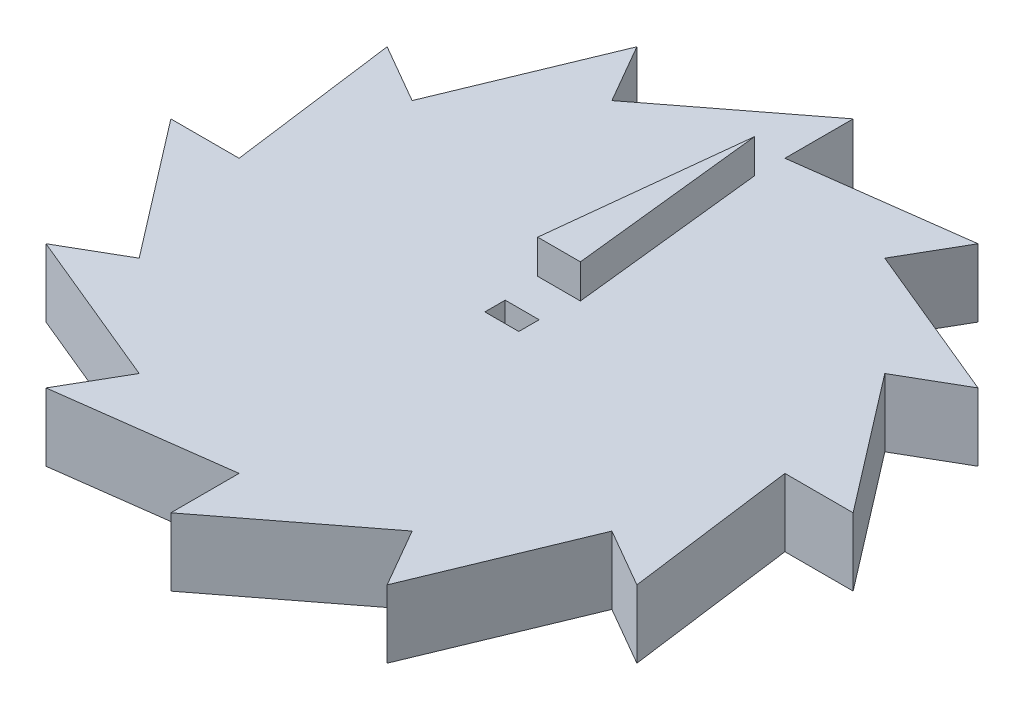
from build123d import *

# Parameters (mm, degrees)
SKETCH2_W           = 5
SKETCH2_H           = 3
BOSS_EXTRUDE2_DEPTH = 10
BOSS_EXTRUDE3_DEPTH = 5


with BuildPart() as part:
    # Sketch2 → Boss-Extrude2 (new body)
    with BuildSketch(Plane(origin=(0, 0, 0), x_dir=(1, 0, 0), z_dir=(0, 1, 0))):
        Polygon((0, 40.223426607), (0, 50.279283258), (-20.111713303, 34.834509269), (-25.139641629, 43.543136586), (-34.834509269, 20.111713303), (-43.543136586, 25.139641629), (-40.223426607, 0), (-50.279283258, 0), (-34.834509269, -20.111713303), (-43.543136586, -25.139641629), (-20.111713303, -34.834509269), (-25.139641629, -43.543136586), (0, -40.223426607), (0, -50.279283258), (20.111713303, -34.834509269), (25.139641629, -43.543136586), (34.834509269, -20.111713303), (43.543136586, -25.139641629), (40.223426607, 0), (50.279283258, 0), (34.834509269, 20.111713303), (43.543136586, 25.139641629), (20.111713303, 34.834509269), (25.139641629, 43.543136586), align=None)
        Rectangle(SKETCH2_W, SKETCH2_H, mode=Mode.SUBTRACT)
    extrude(amount=BOSS_EXTRUDE2_DEPTH)

    # Sketch3 → Boss-Extrude3 (add)
    with BuildSketch(Plane(origin=(0, 10, 0), x_dir=(1, 0, 0), z_dir=(0, 1, 0))):
        Polygon((0, 35.761861209), (-3.15, 6.933446407), (3.15, 6.933446407), align=None)
    extrude(amount=BOSS_EXTRUDE3_DEPTH)


solid = part.part
